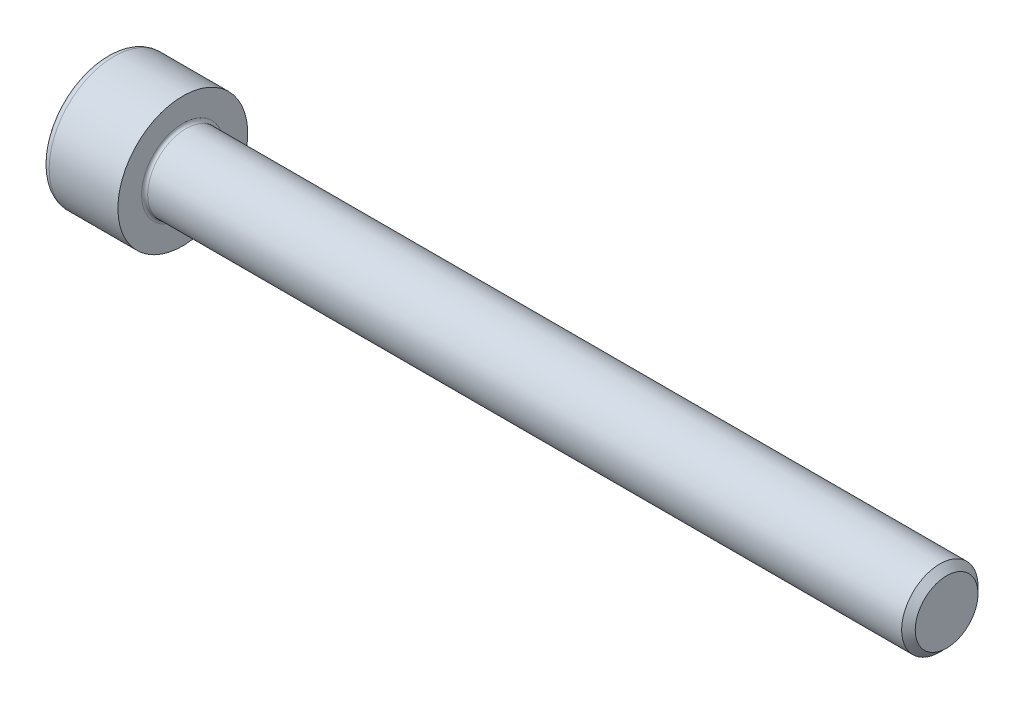
from build123d import *

# Parameters (mm, degrees)
FILLET1_R   = 0.2
FILLET2_R   = 0.5
HEX_2_DEPTH = 2.5


with BuildPart() as part:
    # BodySke → Base-Revolve (revolve)
    with BuildSketch(Plane.XY):
        Polygon((0, 0), (0, 4.25), (5, 4.25), (5, 2.5), (54.555, 2.5), (55, 2.055), (55, 0), align=None)
    revolve(axis=Axis((-31.75, 0, 0), (1, 0, 0)))

    # Fillet1
    fillet1_edges = [part.edges().sort_by_distance(p)[0] for p in [
        (5, -2.5, 0),
    ]]
    fillet(fillet1_edges, radius=FILLET1_R)

    # Fillet2
    fillet2_edges = [part.edges().sort_by_distance(p)[0] for p in [
        (0, -4.25, 0),
    ]]
    fillet(fillet2_edges, radius=FILLET2_R)

    # Sketch2 → Hex-PreBroach (revolve, cut)
    with BuildSketch(Plane.XY):
        Polygon((0, 2.01), (2.5, 2.01), (3.660474041, 0), (0, 0), align=None)
    revolve(axis=Axis((0, 0, 0), (1, 0, 0)), mode=Mode.SUBTRACT)

    # Sketch3 → Hex 2 (cut)
    with BuildSketch(Plane(origin=(0, 0, 0), x_dir=(0, 0.5, 0.866025404), z_dir=(-1, 0, 0))):
        Polygon((1.160474041, 2.01), (-1.160474041, 2.01), (-2.320948082, 0), (-1.160474041, -2.01), (1.160474041, -2.01), (2.320948082, 0), align=None)
    extrude(amount=-HEX_2_DEPTH, mode=Mode.SUBTRACT)


solid = part.part
